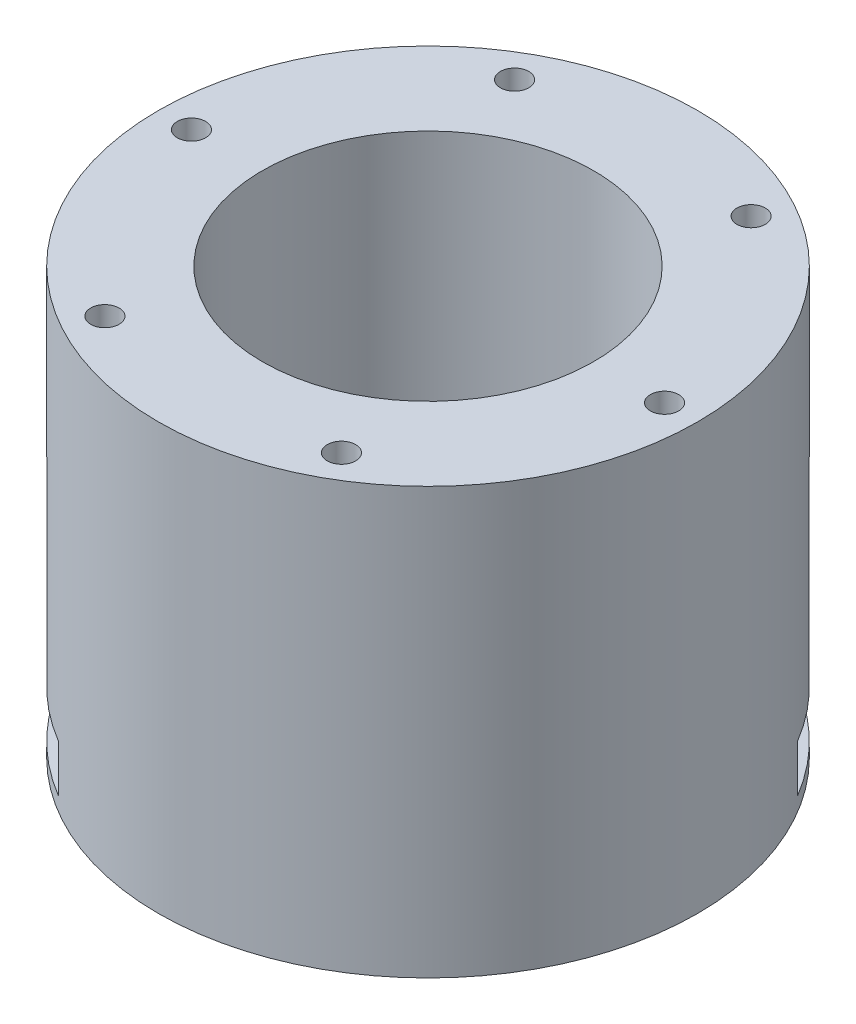
from build123d import *

# Parameters (mm, degrees)
SKETCH_1_R          = 28.5
EXTRUDE_1_DEPTH     = 45
SKETCH_2_R          = 17.5
CUT_EXTRUDE_1_DEPTH = 30
SKETCH_3_R          = 1.5
CUT_EXTRUDE_2_DEPTH = 6
SKETCH_7_W          = 5
SKETCH_7_H          = 14
CUT_EXTRUDE_3_DEPTH = 45
SKETCH_8_W          = 7
SKETCH_8_H          = 9
CUT_EXTRUDE_4_DEPTH = 90
SKETCH_9_R          = 1.5
CUT_EXTRUDE_5_DEPTH = 10


with BuildPart() as part:
    # 草图1 → 凸台-拉伸1 (new body)
    with BuildSketch(Plane(origin=(0, 0, 0), x_dir=(1, 0, 0), z_dir=(0, 1, 0))):
        Circle(SKETCH_1_R)
    extrude(amount=EXTRUDE_1_DEPTH)

    # 草图2 → 切除-拉伸1 (cut)
    with BuildSketch(Plane(origin=(0, 45, 0), x_dir=(1, 0, 0), z_dir=(0, 1, 0))):
        Circle(SKETCH_2_R)
    extrude(amount=-CUT_EXTRUDE_1_DEPTH, mode=Mode.SUBTRACT)

    # 草图3 → 切除-拉伸2 (cut)
    with BuildSketch(Plane.XZ):
        with Locations((-19, 0)):
            Circle(SKETCH_3_R)
        with Locations((0, 19)):
            Circle(SKETCH_3_R)
        with Locations((19, 0)):
            Circle(SKETCH_3_R)
        with Locations((0, -19)):
            Circle(SKETCH_3_R)
    extrude(amount=-CUT_EXTRUDE_2_DEPTH, mode=Mode.SUBTRACT)

    # 草图7 → 切除-拉伸3 (cut, symmetric)
    with BuildSketch(Plane(origin=(0, 0, 0), x_dir=(0, 1, 0), z_dir=(0.7071067811865438, 0, -0.7071067811865512))):
        with Locations((4, 0)):
            Rectangle(SKETCH_7_W, SKETCH_7_H)
    extrude(amount=CUT_EXTRUDE_3_DEPTH, both=True, mode=Mode.SUBTRACT)

    # 草图8 → 切除-拉伸4 (cut)
    with BuildSketch(Plane(origin=(0, 0, 0), x_dir=(0, 1, 0), z_dir=(0.7071067811865488, 0, 0.7071067811865464))):
        with Locations((5, 0)):
            Rectangle(SKETCH_8_W, SKETCH_8_H)
    extrude(amount=-CUT_EXTRUDE_4_DEPTH, mode=Mode.SUBTRACT)

    # 草图9 → 切除-拉伸5 (cut)
    with BuildSketch(Plane(origin=(0, 45, 0), x_dir=(1, 0, 0), z_dir=(0, 1, 0))):
        with Locations((-25, 0)):
            Circle(SKETCH_9_R)
        with Locations((-12.5, 21.650635095)):
            Circle(SKETCH_9_R)
        with Locations((12.5, 21.650635095)):
            Circle(SKETCH_9_R)
        with Locations((25, 0)):
            Circle(SKETCH_9_R)
        with Locations((12.5, -21.650635095)):
            Circle(SKETCH_9_R)
        with Locations((-12.5, -21.650635095)):
            Circle(SKETCH_9_R)
    extrude(amount=-CUT_EXTRUDE_5_DEPTH, mode=Mode.SUBTRACT)


solid = part.part
